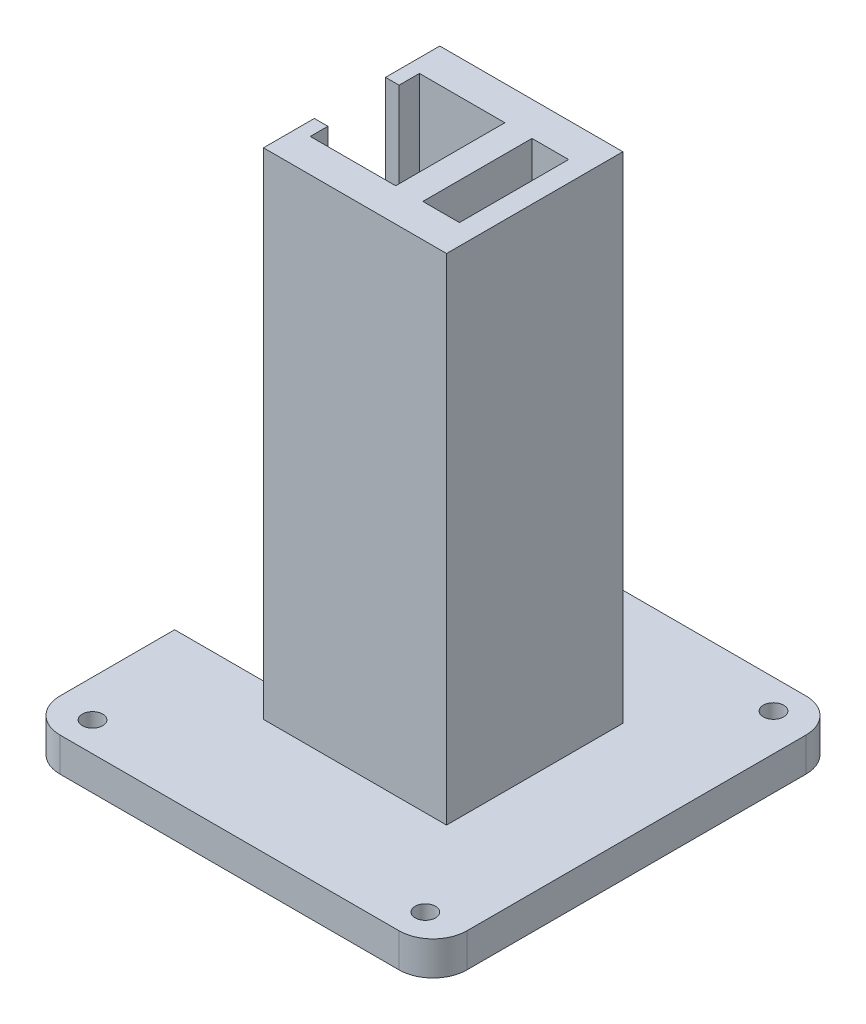
from build123d import *

# Parameters (mm, degrees)
SKETCH1_W           = 30
SKETCH1_H           = 73
BOSS_EXTRUDE1_DEPTH = 26
SKETCH2_W           = 25
SKETCH2_H           = 16.1
CUT_EXTRUDE1_DEPTH  = 74
SKETCH3_W           = 26
SKETCH3_H           = 24
SKETCH3_H_2         = 16.23422306
CUT_EXTRUDE2_DEPTH  = 5
SKETCH5_W           = 60
SKETCH5_H           = 60
BOSS_EXTRUDE2_DEPTH = 5
FILLET1_R           = 5
SKETCH6_R           = 1.5
CUT_EXTRUDE4_DEPTH  = 5
SKETCH7_R           = 1
CUT_EXTRUDE5_DEPTH  = 4
SKETCH8_W           = 15.5
SKETCH8_H           = 5
CUT_EXTRUDE6_DEPTH  = 42
SKETCH9_W           = 5
SKETCH9_H           = 26
CUT_EXTRUDE7_DEPTH  = 73
SKETCH10_W          = 2
SKETCH10_H          = 8
SKETCH10_H_2        = 7.5
BOSS_EXTRUDE3_DEPTH = 78
SKETCH11_W          = 42
SKETCH11_H          = 0.6
CUT_EXTRUDE8_DEPTH  = 6
SKETCH13_W          = 0.6
SKETCH13_H          = 5
BOSS_EXTRUDE5_DEPTH = 2
SKETCH15_W          = 4
SKETCH15_H          = 16.1
BOSS_EXTRUDE6_DEPTH = 78


with BuildPart() as part:
    # Sketch1 → Boss-Extrude1 (new body)
    with BuildSketch(Plane.XY):
        Rectangle(SKETCH1_W, SKETCH1_H)
    extrude(amount=BOSS_EXTRUDE1_DEPTH)

    # Sketch2 → Cut-Extrude1 (cut, through all)
    with BuildSketch(Plane(origin=(0, 36.5, 0), x_dir=(1, 0, 0), z_dir=(0, 1, 0))):
        with Locations((-0.5, -13.05)):
            Rectangle(SKETCH2_W, SKETCH2_H)
    extrude(amount=-CUT_EXTRUDE1_DEPTH, mode=Mode.SUBTRACT)

    # Sketch3 → Cut-Extrude2 (cut)
    with BuildSketch(Plane.ZY.offset(15)):
        with Locations((13, 21.5)):
            Rectangle(SKETCH3_W, SKETCH3_H)
        with Locations((13, -5.5)):
            Rectangle(SKETCH3_W, SKETCH3_H)
        with Locations((13, -28.61711153)):
            Rectangle(SKETCH3_W, SKETCH3_H_2)
    extrude(amount=-CUT_EXTRUDE2_DEPTH, mode=Mode.SUBTRACT)

    # Sketch5 → Boss-Extrude2 (add)
    with BuildSketch(Plane(origin=(0, -36.5, 0), x_dir=(-1, 0, 0), z_dir=(0, -1, 0))):
        with Locations((0, -13)):
            Rectangle(SKETCH5_W, SKETCH5_H)
    extrude(amount=BOSS_EXTRUDE2_DEPTH)

    # Fillet1
    fillet1_edges = [part.edges().sort_by_distance(p)[0] for p in [
        (30, -39, -17),
        (30, -39, 43),
        (-30, -39, 43),
        (-30, -39, -17),
    ]]
    fillet(fillet1_edges, radius=FILLET1_R)

    # Sketch6 → Cut-Extrude4 (cut)
    with BuildSketch(Plane(origin=(0, -36.5, 0), x_dir=(1, 0, 0), z_dir=(0, 1, 0))):
        with Locations((-24.540514854, 12.671548216)):
            Circle(SKETCH6_R)
        with Locations((24.540514854, 12.671548216)):
            Circle(SKETCH6_R)
        with Locations((-24.540514854, -38.671548216)):
            Circle(SKETCH6_R)
        with Locations((24.540514854, -38.671548216)):
            Circle(SKETCH6_R)
    extrude(amount=-CUT_EXTRUDE4_DEPTH, mode=Mode.SUBTRACT)

    # Sketch7 → Cut-Extrude5 (cut)
    with BuildSketch(Plane(origin=(0, 0, 0), x_dir=(-1, 0, 0), z_dir=(0, 0, -1))):
        with Locations((-7, 31.5)):
            Circle(SKETCH7_R)
        with Locations((-12, 24.5)):
            Circle(SKETCH7_R)
        with Locations((-2, 24.5)):
            Circle(SKETCH7_R)
        with Locations((-7, 18.5)):
            Circle(SKETCH7_R)
    extrude(amount=-CUT_EXTRUDE5_DEPTH, mode=Mode.SUBTRACT)

    # Sketch8 → Cut-Extrude6 (cut)
    with BuildSketch(Plane.ZY.offset(30)):
        with Locations((12.75, -39)):
            Rectangle(SKETCH8_W, SKETCH8_H)
    extrude(amount=-CUT_EXTRUDE6_DEPTH, mode=Mode.SUBTRACT)

    # Sketch9 → Cut-Extrude7 (cut)
    with BuildSketch(Plane(origin=(0, 36.5, 0), x_dir=(1, 0, 0), z_dir=(0, 1, 0))):
        with Locations((-12.5, -13)):
            Rectangle(SKETCH9_W, SKETCH9_H)
    extrude(amount=-CUT_EXTRUDE7_DEPTH, mode=Mode.SUBTRACT)

    # Sketch10 → Boss-Extrude3 (add)
    with BuildSketch(Plane(origin=(0, 36.5, 0), x_dir=(1, 0, 0), z_dir=(0, 1, 0))):
        with Locations((-11, -4)):
            Rectangle(SKETCH10_W, SKETCH10_H)
        with Locations((-11, -22.25)):
            Rectangle(SKETCH10_W, SKETCH10_H_2)
    extrude(amount=-BOSS_EXTRUDE3_DEPTH)

    # Sketch11 → Cut-Extrude8 (cut, through all)
    with BuildSketch(Plane(origin=(0, -36.5, 0), x_dir=(1, 0, 0), z_dir=(0, 1, 0))):
        with Locations((-9, -20.8)):
            Rectangle(SKETCH11_W, SKETCH11_H)
    extrude(amount=-CUT_EXTRUDE8_DEPTH, mode=Mode.SUBTRACT)

    # Sketch13 → Boss-Extrude5 (add)
    with BuildSketch(Plane.ZY.offset(12)):
        with Locations((20.8, -39)):
            Rectangle(SKETCH13_W, SKETCH13_H)
    extrude(amount=-BOSS_EXTRUDE5_DEPTH)

    # Sketch15 → Boss-Extrude6 (add)
    with BuildSketch(Plane(origin=(0, 36.5, 0), x_dir=(1, 0, 0), z_dir=(0, 1, 0))):
        with Locations((4.6, -13.05)):
            Rectangle(SKETCH15_W, SKETCH15_H)
    extrude(amount=-BOSS_EXTRUDE6_DEPTH)


solid = part.part
